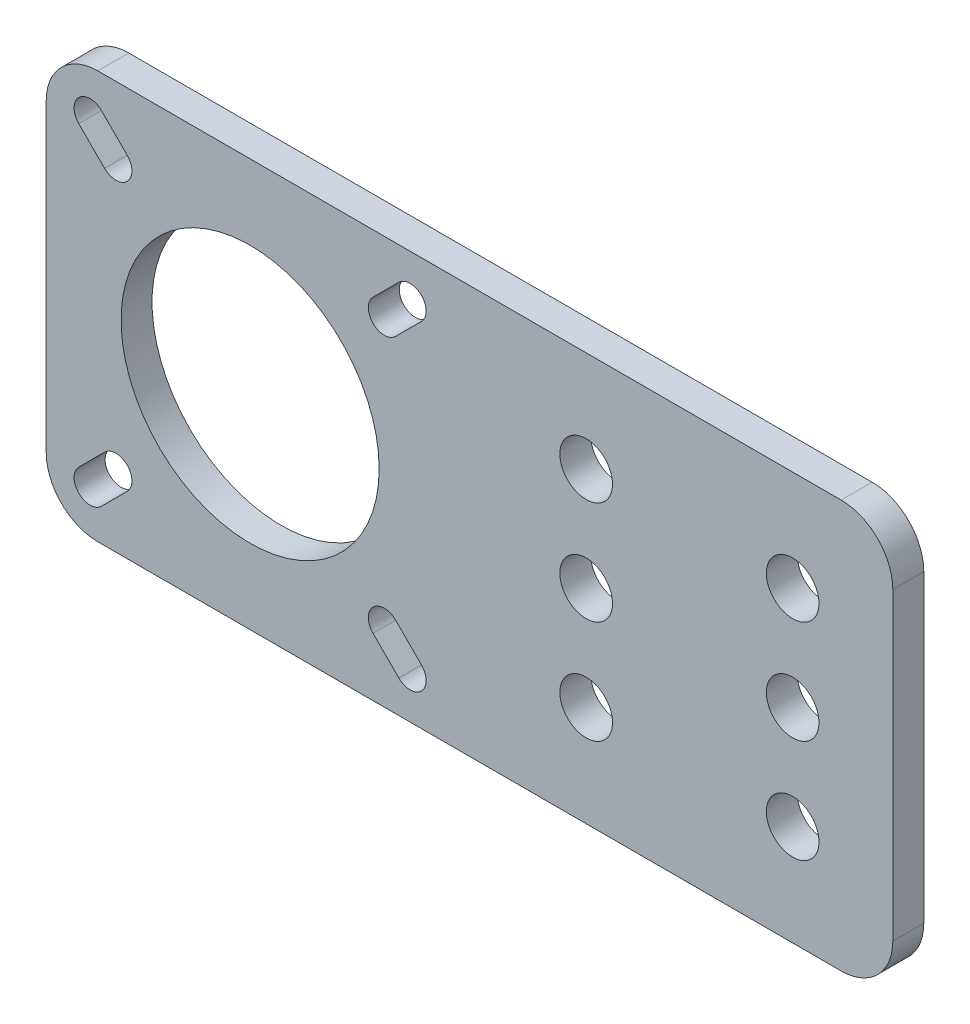
from build123d import *

# Parameters (mm, degrees)
SKETCH1_W           = 82
SKETCH1_H           = 39.5
SKETCH1_R           = 12.5
SKETCH1_R_2         = 2.55
BOSS_EXTRUDE1_DEPTH = 3
FILLET1_R           = 5


with BuildPart() as part:
    # Sketch1 → Boss-Extrude1 (new body)
    with BuildSketch(Plane.XY):
        with Locations((41, 19.75)):
            Rectangle(SKETCH1_W, SKETCH1_H)
        with Locations((19.75, 19.75)):
            Circle(SKETCH1_R, mode=Mode.SUBTRACT)
        with Locations((52.3, 19.75)):
            Circle(SKETCH1_R_2, mode=Mode.SUBTRACT)
        with Locations((52.3, 29.75)):
            Circle(SKETCH1_R_2, mode=Mode.SUBTRACT)
        with Locations((52.3, 9.75)):
            Circle(SKETCH1_R_2, mode=Mode.SUBTRACT)
        with Locations((72.3, 9.75)):
            Circle(SKETCH1_R_2, mode=Mode.SUBTRACT)
        with Locations((72.3, 19.75)):
            Circle(SKETCH1_R_2, mode=Mode.SUBTRACT)
        with Locations((72.3, 29.75)):
            Circle(SKETCH1_R_2, mode=Mode.SUBTRACT)
        with BuildLine():
            Line((5.346015511, 36.346015511), (7.846015511, 33.846015511))
            ThreePointArc((7.846015511, 33.846015511), (7.846015511, 31.653984489), (5.653984489, 31.653984489))
            Line((5.653984489, 31.653984489), (3.153984489, 34.153984489))
            ThreePointArc((3.153984489, 34.153984489), (3.153984489, 36.346015511), (5.346015511, 36.346015511))
        make_face(mode=Mode.SUBTRACT)
        with BuildLine():
            Line((34.153984489, 36.346015511), (31.653984489, 33.846015511))
            ThreePointArc((31.653984489, 33.846015511), (31.653984489, 31.653984489), (33.846015511, 31.653984489))
            Line((33.846015511, 31.653984489), (36.346015511, 34.153984489))
            ThreePointArc((36.346015511, 34.153984489), (36.346015511, 36.346015511), (34.153984489, 36.346015511))
        make_face(mode=Mode.SUBTRACT)
        with BuildLine():
            Line((34.153984489, 3.153984489), (31.653984489, 5.653984489))
            ThreePointArc((31.653984489, 5.653984489), (31.653984489, 7.846015511), (33.846015511, 7.846015511))
            Line((33.846015511, 7.846015511), (36.346015511, 5.346015511))
            ThreePointArc((36.346015511, 5.346015511), (36.346015511, 3.153984489), (34.153984489, 3.153984489))
        make_face(mode=Mode.SUBTRACT)
        with BuildLine():
            Line((5.346015511, 3.153984489), (7.846015511, 5.653984489))
            ThreePointArc((7.846015511, 5.653984489), (7.846015511, 7.846015511), (5.653984489, 7.846015511))
            Line((5.653984489, 7.846015511), (3.153984489, 5.346015511))
            ThreePointArc((3.153984489, 5.346015511), (3.153984489, 3.153984489), (5.346015511, 3.153984489))
        make_face(mode=Mode.SUBTRACT)
    extrude(amount=BOSS_EXTRUDE1_DEPTH)

    # Fillet1
    fillet1_edges = [part.edges().sort_by_distance(p)[0] for p in [
        (0, 39.5, 1.5),
        (82, 39.5, 1.5),
        (82, 0, 1.5),
        (0, 0, 1.5),
    ]]
    fillet(fillet1_edges, radius=FILLET1_R)


solid = part.part
